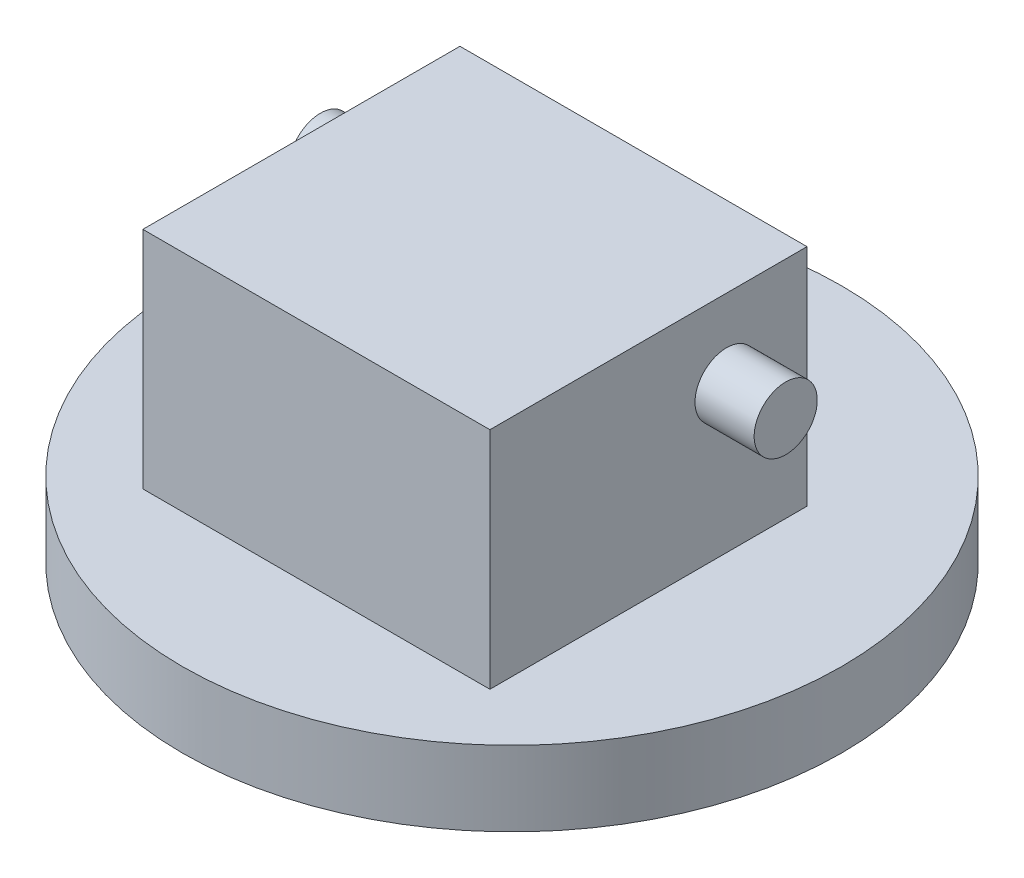
from build123d import *

# Parameters (mm, degrees)
SKETCH1_R           = 41.8
BOSS_EXTRUDE1_DEPTH = 9.5
SKETCH2_W           = 44
SKETCH2_H           = 40.2
BOSS_EXTRUDE2_DEPTH = 28.5
SKETCH3_R           = 4
BOSS_EXTRUDE3_DEPTH = 7.5


with BuildPart() as part:
    # Sketch1 → Boss-Extrude1 (new body)
    with BuildSketch(Plane(origin=(0, 0, 0), x_dir=(1, 0, 0), z_dir=(0, 1, 0))):
        Circle(SKETCH1_R)
    extrude(amount=BOSS_EXTRUDE1_DEPTH)

    # Sketch2 → Boss-Extrude2 (add)
    with BuildSketch(Plane(origin=(0, 9.5, 0), x_dir=(1, 0, 0), z_dir=(0, 1, 0))):
        with Locations((0, -4.7)):
            Rectangle(SKETCH2_W, SKETCH2_H)
    extrude(amount=BOSS_EXTRUDE2_DEPTH)

    # Sketch3 → Boss-Extrude3 (add)
    with BuildSketch(Plane(origin=(22, 0, 0), x_dir=(0, 0, -1), z_dir=(1, 0, 0))):
        with Locations((5.2, 28)):
            Circle(SKETCH3_R)
    boss_extrude3 = extrude(amount=BOSS_EXTRUDE3_DEPTH)

    # Mirror2: Boss-Extrude3 across plane
    add(boss_extrude3.mirror(Plane(origin=(0, 0, 0), x_dir=(0, 0, 1), z_dir=(1, 0, 0))))


solid = part.part
